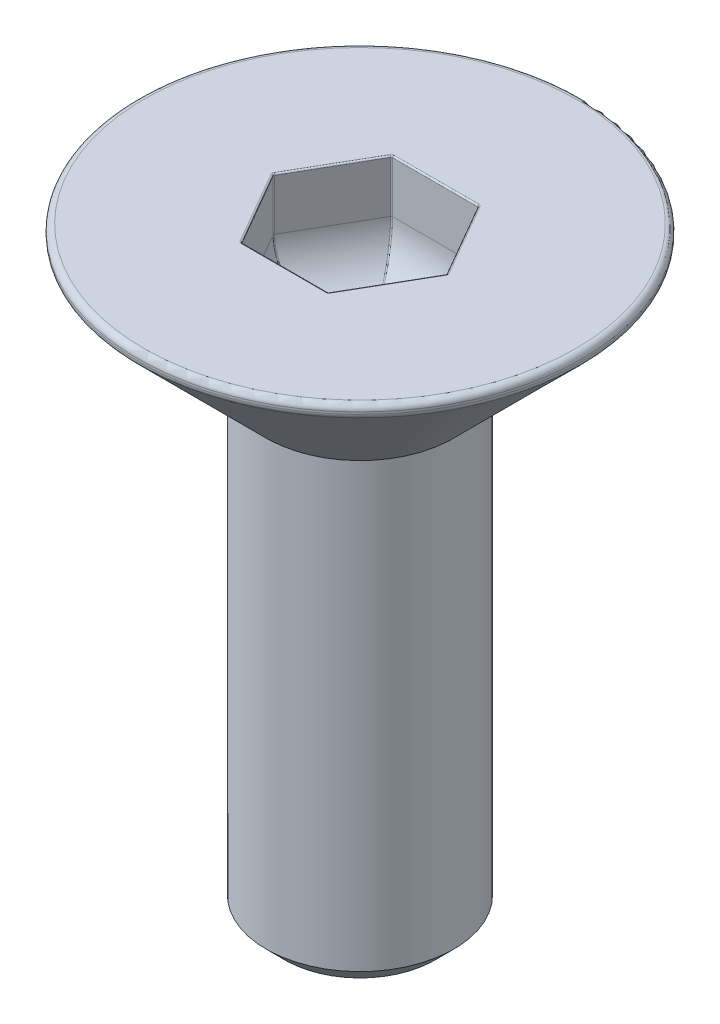
from build123d import *

# Parameters (mm, degrees)
SKETCH8_W          = 1.25
SKETCH8_H          = 8
CHAMFER1_SIZE      = 0.25
CHAMFER2_SIZE2     = 0.2
CHAMFER2_SIZE      = 0.141421
FILLET1_R          = 0.08
CUT_EXTRUDE1_DEPTH = 1.5
FILLET2_R          = 0.8
FILLET5_R          = 0.02


with BuildPart() as part:
    # Sketch8 → Revolve1 (revolve)
    with BuildSketch(Plane.XY):
        with Locations((0.625, -4)):
            Rectangle(SKETCH8_W, SKETCH8_H)
    revolve(axis=Axis((0, 0, 0), (0, -1, 0)))

    # Chamfer1
    chamfer1_edges = [part.edges().sort_by_distance(p)[0] for p in [
        (-1.25, -8, 0),
    ]]
    chamfer(chamfer1_edges, length=CHAMFER1_SIZE)

    # Sketch13 → Revolve2 (revolve)
    with BuildSketch(Plane.XY):
        Polygon((0, 0), (3.1, 0), (0, -3.1), align=None)
    revolve(axis=Axis((0, 0, 0), (0, -1, 0)))

    # Chamfer2
    chamfer2_edges = [part.edges().sort_by_distance(p)[0] for p in [
        (-3.1, 0, 0),
    ]]
    chamfer(chamfer2_edges, length=CHAMFER2_SIZE, length2=CHAMFER2_SIZE2)

    # Fillet1
    fillet1_edges = [part.edges().sort_by_distance(p)[0] for p in [
        (-2.958578, 0, 0),
        (-2.958578, -0.141421, 0),
    ]]
    fillet(fillet1_edges, radius=FILLET1_R)

    # Sketch14 → Cut-Extrude1 (cut)
    with BuildSketch(Plane(origin=(0, 0, 0), x_dir=(1, 0, 0), z_dir=(0, 1, 0))):
        Polygon((1.154701, 0), (0.57735, 1), (-0.57735, 1), (-1.154701, 0), (-0.57735, -1), (0.57735, -1), align=None)
    extrude(amount=-CUT_EXTRUDE1_DEPTH, mode=Mode.SUBTRACT)

    # Fillet2
    fillet2_edges = [part.edges().sort_by_distance(p)[0] for p in [
        (0.866025, -1.5, 0.5),
        (0, -1.5, 1),
        (-0.866025, -1.5, 0.5),
        (-0.866025, -1.5, -0.5),
        (0, -1.5, -1),
        (0.866025, -1.5, -0.5),
    ]]
    fillet(fillet2_edges, radius=FILLET2_R)

    # Fillet5
    fillet5_edges = [part.edges().sort_by_distance(p)[0] for p in [
        (0.866025, 0, 0.5),
        (0.866025, 0, -0.5),
        (0, 0, -1),
        (-0.866025, 0, -0.5),
        (-0.866025, 0, 0.5),
        (0, 0, 1),
        (0.57735, -0.35, 1),
        (-0.57735, -0.35, 1),
        (-1.154701, -0.35, 0),
        (-0.57735, -0.35, -1),
        (0.57735, -0.35, -1),
        (1.154701, -0.35, 0),
        (-0.430209, -1.285507, -0.745143),
        (0.430209, -1.285507, -0.745143),
        (-0.860417, -1.285507, 0),
        (0.860417, -1.285507, 0),
        (-0.430209, -1.285507, 0.745143),
        (0.430209, -1.285507, 0.745143),
    ]]
    fillet(fillet5_edges, radius=FILLET5_R)


solid = part.part
